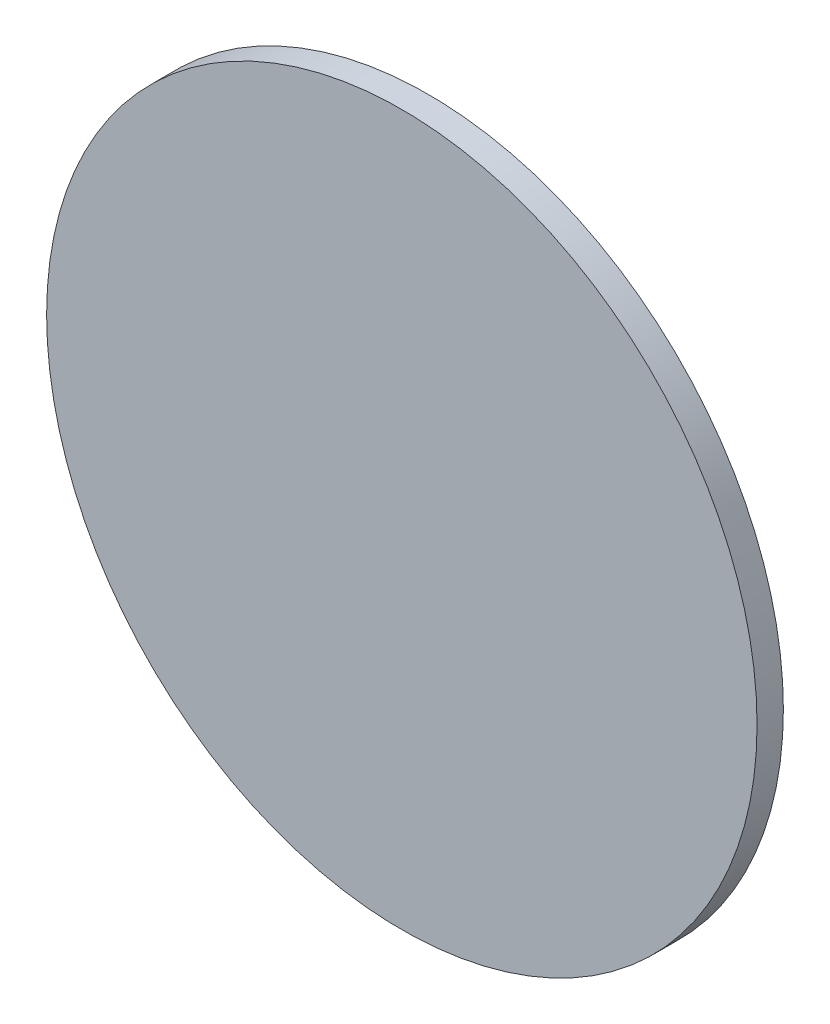
from build123d import *

# Parameters (mm, degrees)
SKETCH1_R           = 27
BOSS_EXTRUDE1_DEPTH = 2


with BuildPart() as part:
    # Sketch1 → Boss-Extrude1 (new body)
    with BuildSketch(Plane.XY):
        Circle(SKETCH1_R)
    extrude(amount=BOSS_EXTRUDE1_DEPTH)


solid = part.part
